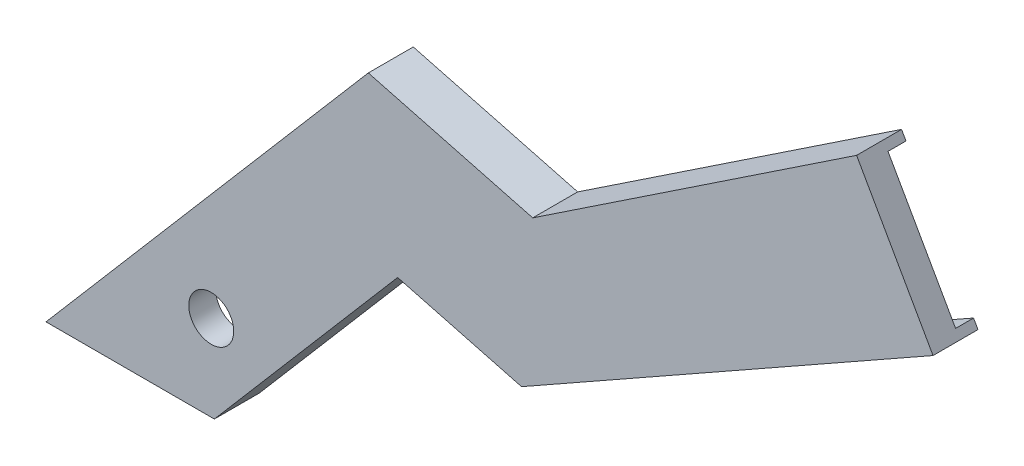
from build123d import *

# Parameters (mm, degrees)
SKETCH1_R           = 5
BOSS_EXTRUDE1_DEPTH = 10
CUT_EXTRUDE1_DEPTH  = 4


with BuildPart() as part:
    # Sketch1 → Boss-Extrude1 (new body)
    with BuildSketch(Plane.XY):
        Polygon((72.027126309, 48.055346158), (89.027642078, 17.992338813), (-2.487468662, -33.759106586), (-30.037099765, -26.499406498), (-70.803107952, -74.152822461), (-108.242490343, -74.152822461), (-36.564435859, 9.635222963), (0, 0), align=None)
        with Locations((-71.49077455, -55.104728104)):
            Circle(SKETCH1_R, mode=Mode.SUBTRACT)
    extrude(amount=-BOSS_EXTRUDE1_DEPTH)

    # Sketch2 → Cut-Extrude1 (cut)
    with BuildSketch(Plane(origin=(0, 0, -10), x_dir=(-1, 0, 0), z_dir=(0, 0, -1))):
        Polygon((-71.346056645, 45.196672444), (-73.014288261, 46.309689884), (-88.043159753, 19.733256545), (-86.30224202, 18.74877422), (2.764141771, -31.617925447), (30.741045074, -24.245633361), (71.72414825, -72.152822461), (73.43508575, -74.152822461), (105.610512545, -74.152822461), (103.899575045, -72.152822461), (35.86049055, 7.381449825), (-0.361020517, -2.163407821), align=None)
    extrude(amount=-CUT_EXTRUDE1_DEPTH, mode=Mode.SUBTRACT)


solid = part.part
